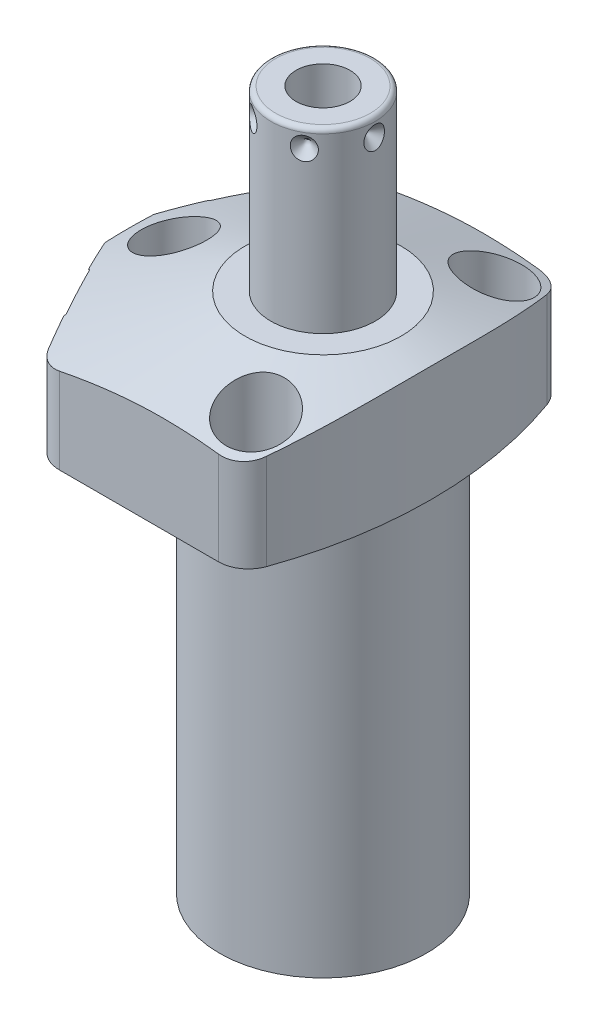
from build123d import *

# Parameters (mm, degrees)
CUT_EXTRUDE1_REACH = 28.975
CUT_EXTRUDE2_REACH = 28.975
S2D0002_OUTSIDE_W  = 122.011
S2D0002_OUTSIDE_H  = 101.742
CUT_EXTRUDE3_DEPTH = 38.0873
FILLET1_R          = 6.35
FILLET2_R          = 6.35
FILLET3_R          = 6.35
SKETCH17_R         = 10.4775
CUT_EXTRUDE4_DEPTH = 0.254
SKETCH18_R         = 5.5626
CUT_EXTRUDE5_DEPTH = 2.667
SKETCH12_R         = 6.4389
EXTRUDE1_DEPTH     = 1.651
EXTRUDE2_START     = -2.667
SKETCH13_R         = 4.8006
EXTRUDE2_DEPTH     = 2.667
CIRPATTERN1_COUNT  = 6
HOLE1_D            = 8.7376
HOLE1_DEPTH        = 26.9748
HOLE1_CBORE_D      = 13.9954
HOLE1_CBORE_DEPTH  = 16.6624


with BuildPart() as part:
    # Sketch1 → Revolve1 (revolve)
    with BuildSketch(Plane(origin=(0, 0, 0), x_dir=(0, -1, 0), z_dir=(0, 0, 1)), mode=Mode.PRIVATE) as revolve1_sk:
        Polygon((0, 44.45), (-26.9748, 44.45), (-26.9748, 0), (84.1502, 0), (84.1502, 22.098), (0, 22.098), align=None)
    revolve(revolve1_sk.sketch.rotate(Axis((0, 32.53105, 0), (0, -1, 0)), 90), axis=Axis((0, 32.53105, 0), (0, -1, 0)))  # turned: the seam where the file's is

    # Sketch2 → Cut-Extrude1 (cut, up to next)
    with BuildSketch(Plane(origin=(0, 0, 0), x_dir=(0, 0, -1), z_dir=(0, -1, 0)), mode=Mode.PRIVATE) as cut_extrude1_sk1:
        with BuildLine():
            Line((34.1122, -28.498426468), (34.1122, 28.498426468))
            ThreePointArc((34.1122, 28.498426468), (44.45, 0), (34.1122, -28.498426468))
        make_face()
    cut_extrude1_tool1 = extrude(cut_extrude1_sk1.sketch, amount=-CUT_EXTRUDE1_REACH, mode=Mode.PRIVATE) & part.part
    add(cut_extrude1_tool1.solids().sort_by_distance((0, 0, -38.291522))[0], mode=Mode.SUBTRACT)
    # Sketch2 → Cut-Extrude1 (cut, up to next)
    with BuildSketch(Plane(origin=(0, 0, 0), x_dir=(0, 0, -1), z_dir=(0, -1, 0)), mode=Mode.PRIVATE) as cut_extrude1_sk2:
        with BuildLine():
            Line((-34.1122, 28.498426468), (-34.1122, -28.498426468))
            ThreePointArc((-34.1122, -28.498426468), (-44.45, 0), (-34.1122, 28.498426468))
        make_face()
    cut_extrude1_tool2 = extrude(cut_extrude1_sk2.sketch, amount=-CUT_EXTRUDE1_REACH, mode=Mode.PRIVATE) & part.part
    add(cut_extrude1_tool2.solids().sort_by_distance((0, 0, 38.291522))[0], mode=Mode.SUBTRACT)

    # Sketch3 → Cut-Extrude2 (cut, up to next)
    with BuildSketch(Plane(origin=(0, 0, 0), x_dir=(-1, 0, 0), z_dir=(0, -1, 0)), mode=Mode.PRIVATE) as cut_extrude2_sk1:
        with BuildLine():
            Line((25.904926114, 34.1122), (44.042704589, 0))
            Line((44.042704589, 0), (25.904926114, -34.1122))
            Line((25.904926114, -34.1122), (28.498426468, -34.1122))
            ThreePointArc((28.498426468, -34.1122), (44.45, 0), (28.498426468, 34.1122))
            Line((28.498426468, 34.1122), (25.904926114, 34.1122))
        make_face()
    cut_extrude2_tool1 = extrude(cut_extrude2_sk1.sketch, amount=-CUT_EXTRUDE2_REACH, mode=Mode.PRIVATE) & part.part
    add(cut_extrude2_tool1.solids().sort_by_distance((-27.201676, 0, -33.4052))[0], mode=Mode.SUBTRACT)

    # S2D0002 outside → Cut-Extrude3 (cut)
    with BuildSketch(Plane(origin=(0, 0, 0), x_dir=(-1, 0, 0), z_dir=(0, -1, 0))):
        with Locations((-0.2035, 0)):
            Rectangle(S2D0002_OUTSIDE_W, S2D0002_OUTSIDE_H)
        with BuildLine():
            Line((41.275, 85.424995881), (41.275, -85.424995881))
            ThreePointArc((41.275, -85.424995881), (-23.0124, 0), (41.275, 85.424995881))
        make_face(mode=Mode.SUBTRACT)
    extrude(amount=-CUT_EXTRUDE3_DEPTH, mode=Mode.SUBTRACT)

    # Fillet1
    fillet1_edges = [part.edges().sort_by_distance(p)[0] for p in [
        (16.207270797, 13.4874, 34.1122),
        (16.207270797, 13.4874, -34.1122),
    ]]
    fillet(fillet1_edges, radius=FILLET1_R)

    # Fillet2
    fillet2_edges = [part.edges().sort_by_distance(p)[0] for p in [
        (-25.904926114, 13.4874, 34.1122),
    ]]
    fillet(fillet2_edges, radius=FILLET2_R)

    # Fillet3
    fillet3_edges = [part.edges().sort_by_distance(p)[0] for p in [
        (-25.904926114, 13.4874, -34.1122),
    ]]
    fillet(fillet3_edges, radius=FILLET3_R)

    # Sketch5 → Cut-Revolve1 (revolve, cut)
    with BuildSketch(Plane.XY, mode=Mode.PRIVATE) as cut_revolve1_sk:
        Polygon((-16.637, 26.9748), (-47.625, 15.696090381), (-47.625, 26.9748), align=None)
    revolve(cut_revolve1_sk.sketch.rotate(Axis((0, 7.66490951, 0), (0, 1, 0)), 90), axis=Axis((0, 7.66490951, 0), (0, 1, 0)), mode=Mode.SUBTRACT)  # turned: the seam where the file's is

    # Sketch6 → Cut-Revolve2 (revolve, cut)
    with BuildSketch(Plane(origin=(-34.111267534, 10.287, -18.137282674), x_dir=(0.469471563, 0, -0.882947593), z_dir=(0, 1, 0))):
        Polygon((0, 0), (6.1849, 0), (5.642306865, -2.5527), (4.9784, -3.216606865), (4.9784, -15.748), (0, -15.748), align=None)
    revolve(axis=Axis((-19.511375907, 10.287, -10.374382594), (-0.882947593, 0, -0.469471563)), mode=Mode.SUBTRACT)

    # Sketch7 → Cut-Revolve3 (revolve, cut)
    with BuildSketch(Plane(origin=(-34.111267534, 10.287, 18.137282674), x_dir=(-0.469471563, 0, -0.882947593), z_dir=(0, 1, 0))):
        Polygon((0, 0), (6.1849, 0), (5.642306865, -2.5527), (4.9784, -3.216606865), (4.9784, -15.748), (0, -15.748), align=None)
    revolve(axis=Axis((-19.511375907, 10.287, 10.374382594), (-0.882947593, 0, 0.469471563)), mode=Mode.SUBTRACT)

    # Sketch8 → Cut-Revolve4 (revolve, cut)
    with BuildSketch(Plane(origin=(-13.4874, 2.667, -26.5938), x_dir=(-1, 0, 0), z_dir=(0, 0, 1)), mode=Mode.PRIVATE) as cut_revolve4_sk:
        Polygon((0, 0), (4.5466, 0), (4.106586662, -2.0701), (3.4544, -2.722286662), (3.4544, -12.573), (0, -12.573), align=None)
    revolve(cut_revolve4_sk.sketch.rotate(Axis((-13.4874, 15.86865, -26.5938), (0, -1, 0)), 270), axis=Axis((-13.4874, 15.86865, -26.5938), (0, -1, 0)), mode=Mode.SUBTRACT)  # turned: the seam where the file's is

    # Sketch9 → Cut-Revolve5 (revolve, cut)
    with BuildSketch(Plane(origin=(-13.4874, 2.667, 26.5938), x_dir=(-1, 0, 0), z_dir=(0, 0, 1)), mode=Mode.PRIVATE) as cut_revolve5_sk:
        Polygon((0, 0), (4.5466, 0), (4.106586662, -2.0701), (3.4544, -2.722286662), (3.4544, -12.573), (0, -12.573), align=None)
    revolve(cut_revolve5_sk.sketch.rotate(Axis((-13.4874, 15.86865, 26.5938), (0, -1, 0)), 270), axis=Axis((-13.4874, 15.86865, 26.5938), (0, -1, 0)), mode=Mode.SUBTRACT)  # turned: the seam where the file's is

    # Sketch17 → Cut-Extrude4 (cut)
    with BuildSketch(Plane(origin=(-34.335536223, 0, 18.256528451), x_dir=(0.469471563, 0, 0.882947593), z_dir=(-0.882947593, 0, 0.469471563))):
        with Locations((0, 10.287)):
            Circle(SKETCH17_R)
    cut_extrude4 = extrude(amount=-CUT_EXTRUDE4_DEPTH, mode=Mode.SUBTRACT)

    # Sketch18 → Cut-Extrude5 (cut)
    with BuildSketch(Plane.XZ):
        with Locations(Location((-13.4874, 26.5938, 0), (0, 0, 270))):  # turned: the seam where the file's is
            Circle(SKETCH18_R)
    cut_extrude5 = extrude(amount=-CUT_EXTRUDE5_DEPTH, mode=Mode.SUBTRACT)

    # Mirror1: Cut-Extrude4, Cut-Extrude5 across plane
    add(cut_extrude4.mirror(Plane.XY), mode=Mode.SUBTRACT)
    add(cut_extrude5.mirror(Plane.XY), mode=Mode.SUBTRACT)

    # Sketch10 → Revolve2 (revolve)
    with BuildSketch(Plane(origin=(0, 0, 0), x_dir=(0, 0, -1), z_dir=(1, 0, 0)), mode=Mode.PRIVATE) as revolve2_sk:
        with BuildLine():
            Line((0, 26.9748), (-11.1125, 26.9748))
            Line((-11.1125, 26.9748), (-11.1125, 63.8302))
            ThreePointArc((-11.1125, 63.8302), (-10.81492049, 64.54862049), (-10.0965, 64.8462))
            Line((-10.0965, 64.8462), (0, 64.8462))
            Line((0, 64.8462), (0, 26.9748))
        make_face()
    revolve(revolve2_sk.sketch.rotate(Axis((0, 14.351681477, 0), (0, 1, 0)), 180), axis=Axis((0, 14.351681477, 0), (0, 1, 0)))  # turned: the seam where the file's is

    # S2D0001 → Cut-Revolve6 (revolve, cut)
    with BuildSketch(Plane(origin=(5.7531, 64.8462, 0), x_dir=(1, 0, 0), z_dir=(0, 0, 1)), mode=Mode.PRIVATE) as cut_revolve6_sk:
        Polygon((0, 0), (0, -17.018), (-5.7531, -20.474811227), (-5.7531, 0), align=None)
    revolve(cut_revolve6_sk.sketch.rotate(Axis((0, 37.109882775, 0), (0, 1, 0)), 90), axis=Axis((0, 37.109882775, 0), (0, 1, 0)), mode=Mode.SUBTRACT)  # turned: the seam where the file's is

    # Sketch12 → Extrude1 (add)
    with BuildSketch(Plane(origin=(-34.111267534, 0, -18.137282674), x_dir=(-0.469471563, 0, 0.882947593), z_dir=(-0.882947593, 0, -0.469471563))):
        with Locations((0, 10.287)):
            Circle(SKETCH12_R)
    extrude(amount=EXTRUDE1_DEPTH)

    # Sketch13 → Extrude2 (add)
    with BuildSketch(Plane.XZ.offset(EXTRUDE2_START)):
        with Locations(Location((-13.4874, -26.5938, 0), (0, 0, 270))):  # turned: the seam where the file's is
            Circle(SKETCH13_R)
    extrude(amount=EXTRUDE2_DEPTH)

    # Sketch14 → Revolve3 (revolve)
    with BuildSketch(Plane(origin=(-13.4874, 0, 26.5938), x_dir=(0, 0, -1), z_dir=(1, 0, 0))):
        with BuildLine():
            Line((5.461, 2.667), (5.461, 0.9398))
            Line((5.461, 0.9398), (5.301559456, 0.9398))
            ThreePointArc((5.301559456, 0.9398), (4.572, -0.4572), (3.842440544, 0.9398))
            Line((3.842440544, 0.9398), (3.175, 0.9398))
            ThreePointArc((3.175, 0.9398), (2.815789755, 0.791010245), (2.667, 0.4318))
            Line((2.667, 0.4318), (2.667, 0.127))
            Line((2.667, 0.127), (1.5875, 0.127))
            Line((1.5875, 0.127), (1.5875, 10.6172))
            Line((1.5875, 10.6172), (3.2512, 10.6172))
            Line((3.2512, 10.6172), (3.2512, 2.667))
            Line((3.2512, 2.667), (5.461, 2.667))
        make_face()
    revolve(axis=Axis((-13.4874, -1.01092, 26.5938), (0, 1, 0)))

    # Sketch15 → Cut-Revolve7 (revolve, cut)
    with BuildSketch(Plane(origin=(-11.1125, 60.8838, 0), x_dir=(0, 1, 0), z_dir=(0, 0, 1)), mode=Mode.PRIVATE) as cut_revolve7_sk:
        Polygon((0, 0), (2.413, 0), (0, -2.413), align=None)
    cut_revolve7 = revolve(cut_revolve7_sk.sketch.rotate(Axis((-6.003069898, 60.8838, 0), (-1, 0, 0)), 270), axis=Axis((-6.003069898, 60.8838, 0), (-1, 0, 0)), mode=Mode.SUBTRACT)  # turned: the seam where the file's is

    # CirPattern1: Cut-Revolve7 ×6 about axis
    cirpattern1_axis = Axis((0, 14.351681477, 0), (0, -1, 0))
    for i in range(1, CIRPATTERN1_COUNT):
        add(cut_revolve7.rotate(cirpattern1_axis, i * 360 / CIRPATTERN1_COUNT), mode=Mode.SUBTRACT)

    # Hole1
    with Locations(Plane(origin=(0, 26.9748, 0), x_dir=(-1, 0, 0), z_dir=(0, 1, 0))):
        with Locations((-11.1252, -25.4), (31.75, 0), (-11.1252, 25.4)):
            CounterBoreHole(HOLE1_D / 2, HOLE1_CBORE_D / 2, HOLE1_CBORE_DEPTH, depth=HOLE1_DEPTH)


solid = part.part
